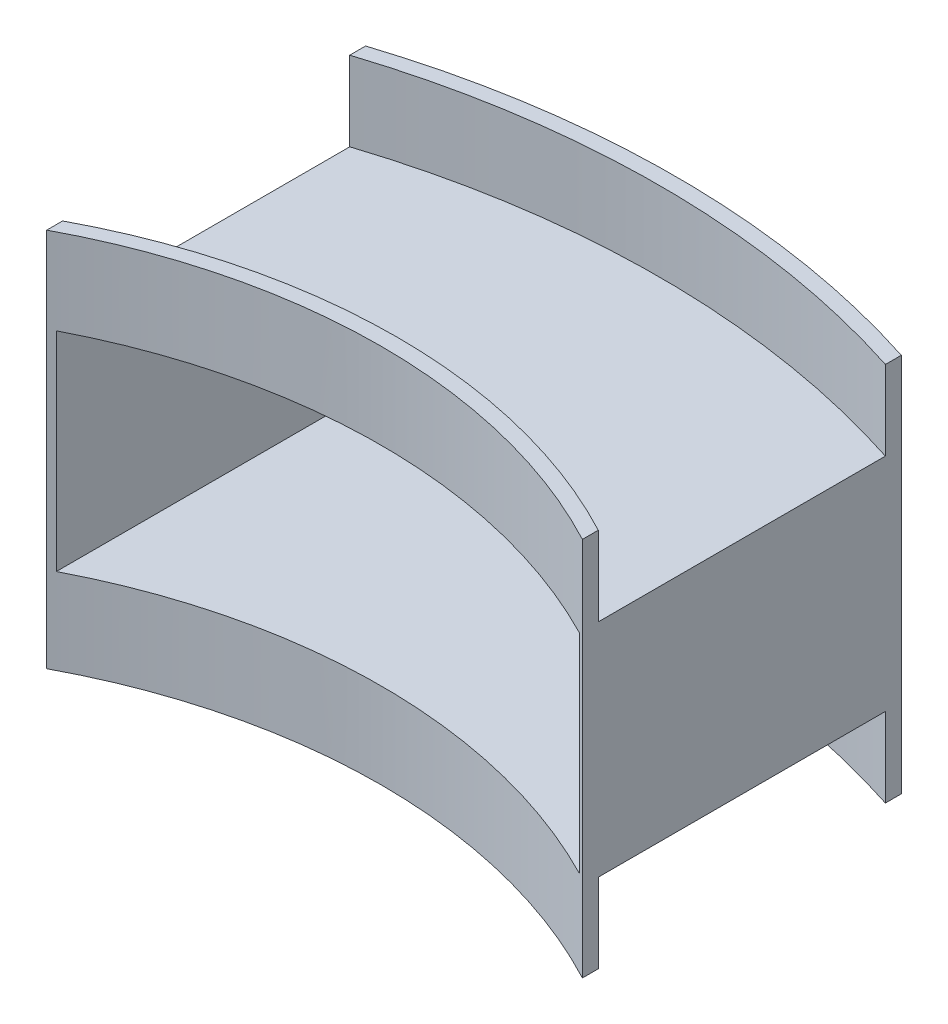
from build123d import *

# Parameters (mm, degrees)
SKETCH1_W           = 33.746
SKETCH1_H           = 13.93
SKETCH1_W_2         = 32.946
SKETCH1_H_2         = 13.13
BOSS_EXTRUDE1_DEPTH = 11.37
CUT_EXTRUDE1_DEPTH  = 25.658060122
BOSS_EXTRUDE2_DEPTH = 5
BOSS_EXTRUDE3_DEPTH = 5


with BuildPart() as part:
    # Sketch1 → Boss-Extrude1 (new, symmetric)
    with BuildSketch(Plane.XY):
        Rectangle(SKETCH1_W, SKETCH1_H)
        Rectangle(SKETCH1_W_2, SKETCH1_H_2, mode=Mode.SUBTRACT)
    extrude(amount=BOSS_EXTRUDE1_DEPTH, both=True)

    # Sketch3 → Cut-Extrude1 (cut, through all)
    with BuildSketch(Plane(origin=(0, 6.965, 0), x_dir=(1, 0, 0), z_dir=(0, 1, 0))):
        with BuildLine():
            ThreePointArc((0, 11.37), (8.54007907, 10.702927857), (16.873, 8.717892708))
            Line((16.873, 8.717892708), (16.873, 11.37))
            Line((16.873, 11.37), (0, 11.37))
        make_face()
        with BuildLine():
            Line((-16.873, 11.37), (-16.873, 8.717892708))
            ThreePointArc((-16.873, 8.717892708), (-8.54007907, 10.702927857), (0, 11.37))
            Line((0, 11.37), (-16.873, 11.37))
        make_face()
        with BuildLine():
            ThreePointArc((16.873, -11.37), (0, -7.1709728), (-16.873, -11.37))
            Line((-16.873, -11.37), (16.873, -11.37))
        make_face()
    extrude(amount=-CUT_EXTRUDE1_DEPTH, mode=Mode.SUBTRACT)

    # Sketch4 → Boss-Extrude2 (add)
    with BuildSketch(Plane(origin=(0, 6.965, 0), x_dir=(1, 0, 0), z_dir=(0, 1, 0))):
        with BuildLine():
            Line((-16.873, -11.37), (-16.873, -10.37))
            ThreePointArc((-16.873, -10.37), (0, -6.1709728), (16.873, -10.37))
            Line((16.873, -10.37), (16.873, -11.37))
            ThreePointArc((16.873, -11.37), (0, -7.1709728), (-16.873, -11.37))
        make_face()
        with BuildLine():
            Line((-16.873, 8.717892708), (-16.873, 7.717892708))
            ThreePointArc((-16.873, 7.717892708), (0, 10.37), (16.873, 7.717892708))
            Line((16.873, 7.717892708), (16.873, 8.717892708))
            ThreePointArc((16.873, 8.717892708), (0, 11.37), (-16.873, 8.717892708))
        make_face()
    extrude(amount=BOSS_EXTRUDE2_DEPTH)

    # Sketch5 → Boss-Extrude3 (add)
    with BuildSketch(Plane.XZ.offset(6.965)):
        with BuildLine():
            Line((-16.873, 11.37), (-16.873, 10.37))
            ThreePointArc((-16.873, 10.37), (0, 6.1709728), (16.873, 10.37))
            Line((16.873, 10.37), (16.873, 11.37))
            ThreePointArc((16.873, 11.37), (0, 7.1709728), (-16.873, 11.37))
        make_face()
        with BuildLine():
            Line((-16.873, -8.717892708), (-16.873, -7.717892708))
            ThreePointArc((-16.873, -7.717892708), (0, -10.37), (16.873, -7.717892708))
            Line((16.873, -7.717892708), (16.873, -8.717892708))
            ThreePointArc((16.873, -8.717892708), (0, -11.37), (-16.873, -8.717892708))
        make_face()
    extrude(amount=BOSS_EXTRUDE3_DEPTH)


solid = part.part
